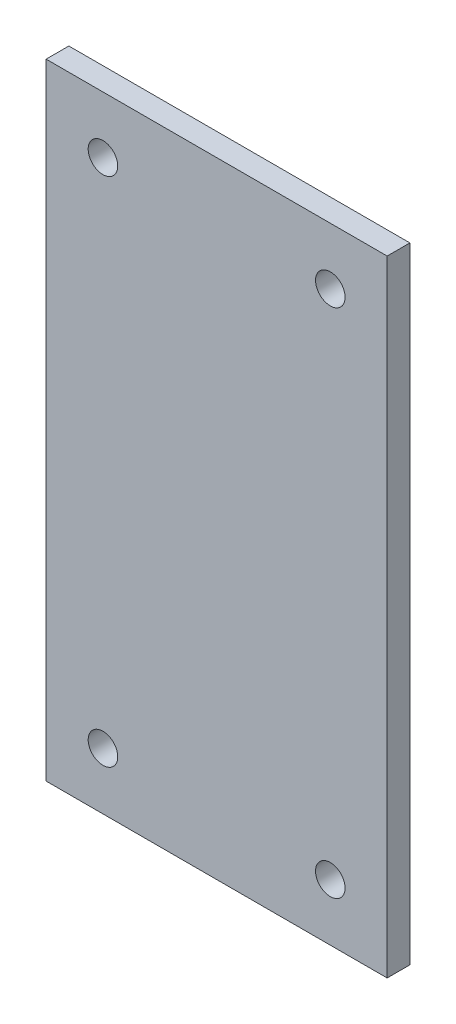
from build123d import *

# Parameters (mm, degrees)
SKETCH_1_W      = 300
SKETCH_1_H      = 550
SKETCH_1_R      = 13
EXTRUDE_1_DEPTH = 20


with BuildPart() as part:
    # Эскиз1 → Бобышка-Вытянуть1 (new body)
    with BuildSketch(Plane.XY):
        Rectangle(SKETCH_1_W, SKETCH_1_H)
        with Locations((-100, 225)):
            Circle(SKETCH_1_R, mode=Mode.SUBTRACT)
        with Locations((100, 225)):
            Circle(SKETCH_1_R, mode=Mode.SUBTRACT)
        with Locations((100, -225)):
            Circle(SKETCH_1_R, mode=Mode.SUBTRACT)
        with Locations((-100, -225)):
            Circle(SKETCH_1_R, mode=Mode.SUBTRACT)
    extrude(amount=EXTRUDE_1_DEPTH)


solid = part.part
